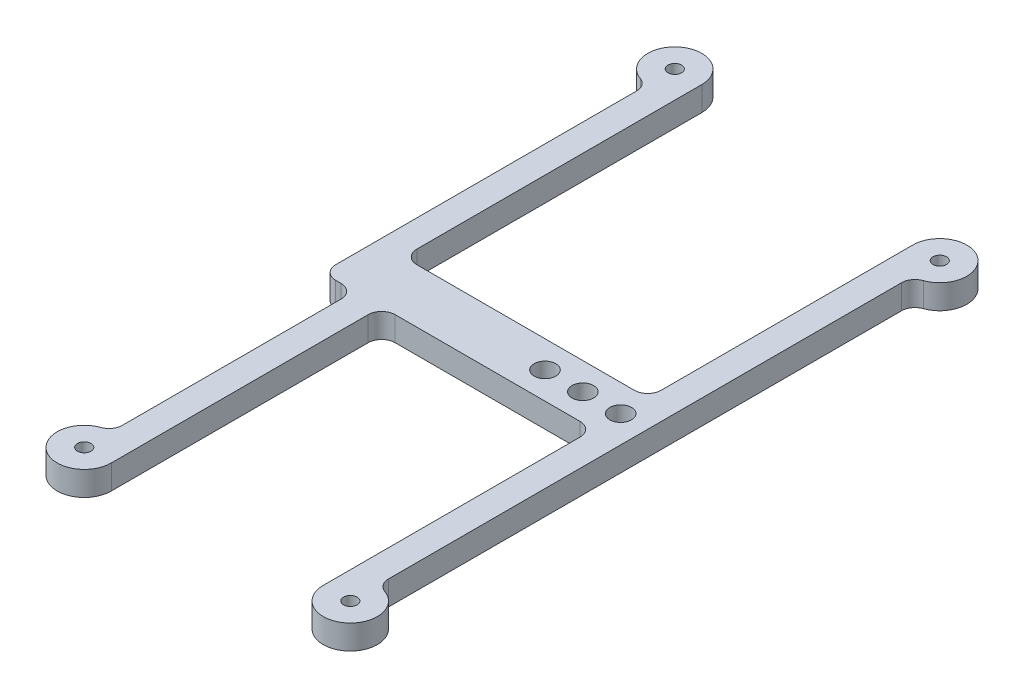
from build123d import *

# Parameters (mm, degrees)
SKETCH1_R           = 1.25
SKETCH1_R_2         = 2
BOSS_EXTRUDE1_DEPTH = 4.5
FILLET5_R           = 2.5


with BuildPart() as part:
    # Sketch1 → Boss-Extrude1 (new body)
    with BuildSketch(Plane(origin=(0, 0, 0), x_dir=(1, 0, 0), z_dir=(0, 1, 0))):
        with BuildLine():
            Line((-6, 50), (0, 50))
            Line((0, 50), (0, 5))
            ThreePointArc((0, 5), (-3.535533906, -3.535533906), (5, 0))
            Line((5, 0), (5, 50))
            Line((5, 50), (44.2, 50))
            Line((44.2, 50), (44.2, 0))
            ThreePointArc((44.2, 0), (52.735533906, -3.535533906), (49.2, 5))
            Line((49.2, 5), (49.2, 50))
            Line((49.2, 50), (49.2, 60))
            Line((49.2, 60), (49.2, 104))
            ThreePointArc((49.2, 104), (52.735533906, 112.535533906), (44.2, 109))
            Line((44.2, 109), (44.2, 60))
            Line((44.2, 60), (-1, 60))
            Line((-1, 60), (-1, 115.2))
            ThreePointArc((-1, 115.2), (-9.535533906, 118.735533906), (-6, 110.2))
            Line((-6, 110.2), (-6, 60))
            Line((-6, 60), (-6, 50))
        make_face()
        Circle(SKETCH1_R, mode=Mode.SUBTRACT)
        with Locations((49.2, 0)):
            Circle(SKETCH1_R, mode=Mode.SUBTRACT)
        with Locations((30.2, 55)):
            Circle(SKETCH1_R_2, mode=Mode.SUBTRACT)
        with Locations((37.2, 55)):
            Circle(SKETCH1_R_2, mode=Mode.SUBTRACT)
        with Locations((44.2, 55)):
            Circle(SKETCH1_R_2, mode=Mode.SUBTRACT)
        with Locations((-6, 115.2)):
            Circle(SKETCH1_R, mode=Mode.SUBTRACT)
        with Locations((49.2, 109)):
            Circle(SKETCH1_R, mode=Mode.SUBTRACT)
    extrude(amount=BOSS_EXTRUDE1_DEPTH)

    # Fillet5
    fillet5_edges = [part.edges().sort_by_distance(p)[0] for p in [
        (-1, 2.25, -60),
        (44.2, 2.25, -60),
        (49.2, 2.25, -104),
        (49.2, 2.25, -5),
        (44.2, 2.25, -50),
        (5, 2.25, -50),
        (0, 2.25, -5),
        (0, 2.25, -50),
        (-6, 2.25, -50),
        (-6, 2.25, -110.2),
    ]]
    fillet(fillet5_edges, radius=FILLET5_R)


solid = part.part
